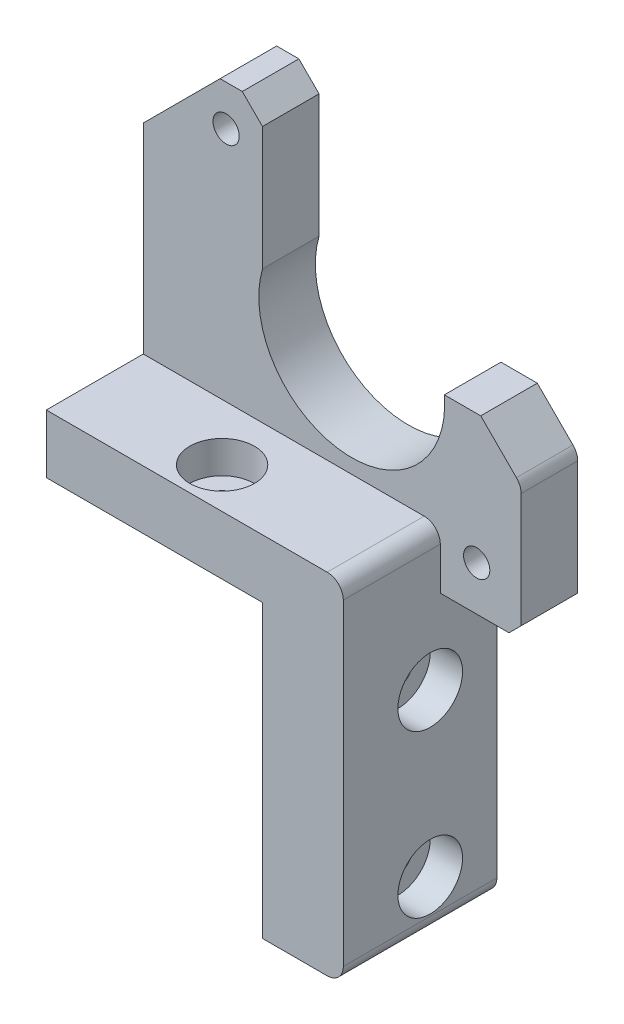
from build123d import *

# Parameters (mm, degrees)
BOSS_EXTRUDE1_DEPTH = 19
BOSS_EXTRUDE2_DEPTH = 7
SKETCH3_R           = 1.75
CUT_EXTRUDE1_DEPTH  = 37.75
SKETCH6_R           = 4
CUT_EXTRUDE4_DEPTH  = 4
SKETCH7_R           = 1.625
CUT_EXTRUDE5_DEPTH  = 20
FILLET1_R           = 2
SKETCH8_R           = 1.75
CUT_EXTRUDE6_DEPTH  = 10
SKETCH9_R           = 4
CUT_EXTRUDE7_DEPTH  = 4


with BuildPart() as part:
    # Sketch1 → Boss-Extrude1 (new body)
    with BuildSketch(Plane.XY):
        Polygon((0, 0), (10, 0), (10, 43.25), (-26.75, 43.25), (-26.75, 36), (0, 36), align=None)
    extrude(amount=BOSS_EXTRUDE1_DEPTH)

    # Sketch2 → Boss-Extrude2 (add)
    with BuildSketch(Plane(origin=(0, 0, 0), x_dir=(-1, 0, 0), z_dir=(0, 0, -1))):
        with BuildLine():
            Line((-10, 36), (26.75, 36))
            Line((26.75, 36), (26.75, 68))
            Line((26.75, 68), (17.25, 77.5))
            Line((17.25, 77.5), (14.5, 77.5))
            Line((14.5, 77.5), (12, 75))
            Line((12, 75), (12, 59.75))
            ThreePointArc((12, 59.75), (2.103531724, 45.089682755), (-10.5, 57.5))
            Line((-10.5, 57.5), (-15, 57.5))
            Line((-15, 57.5), (-20, 52.5))
            Line((-20, 52.5), (-20, 37.5))
            Line((-20, 37.5), (-18.5, 36))
            Line((-18.5, 36), (-10, 36))
        make_face()
    extrude(amount=-BOSS_EXTRUDE2_DEPTH)

    # Sketch3 → Cut-Extrude1 (cut, through all)
    with BuildSketch(Plane(origin=(10, 0, 0), x_dir=(0, 0, -1), z_dir=(1, 0, 0))):
        with Locations((-8.25, 26.25)):
            Circle(SKETCH3_R)
        with Locations((-8.25, 6.25)):
            Circle(SKETCH3_R)
    extrude(amount=-CUT_EXTRUDE1_DEPTH, mode=Mode.SUBTRACT)

    # Sketch6 → Cut-Extrude4 (cut)
    with BuildSketch(Plane(origin=(10, 0, 0), x_dir=(0, 0, -1), z_dir=(1, 0, 0))):
        with Locations((-8.25, 26.25)):
            Circle(SKETCH6_R)
        with Locations((-8.25, 6.25)):
            Circle(SKETCH6_R)
    extrude(amount=-CUT_EXTRUDE4_DEPTH, mode=Mode.SUBTRACT)

    # Sketch7 → Cut-Extrude5 (cut, through all)
    with BuildSketch(Plane(origin=(0, 0, 0), x_dir=(-1, 0, 0), z_dir=(0, 0, -1))):
        with Locations((16.5, 72.5)):
            Circle(SKETCH7_R)
        with Locations((-14.5, 41.5)):
            Circle(SKETCH7_R)
    extrude(amount=-CUT_EXTRUDE5_DEPTH, mode=Mode.SUBTRACT)

    # Fillet1
    fillet1_edges = [part.edges().sort_by_distance(p)[0] for p in [
        (10, 43.25, 13),
        (10, 0, 9.5),
        (20, 52.5, 3.5),
    ]]
    fillet(fillet1_edges, radius=FILLET1_R)

    # Sketch8 → Cut-Extrude6 (cut)
    with BuildSketch(Plane.XZ.offset(-36)):
        with Locations((-10, 14)):
            Circle(SKETCH8_R)
    extrude(amount=-CUT_EXTRUDE6_DEPTH, mode=Mode.SUBTRACT)

    # Sketch9 → Cut-Extrude7 (cut)
    with BuildSketch(Plane(origin=(0, 43.25, 0), x_dir=(1, 0, 0), z_dir=(0, 1, 0))):
        with Locations((-10, -14)):
            Circle(SKETCH9_R)
    extrude(amount=-CUT_EXTRUDE7_DEPTH, mode=Mode.SUBTRACT)


solid = part.part
